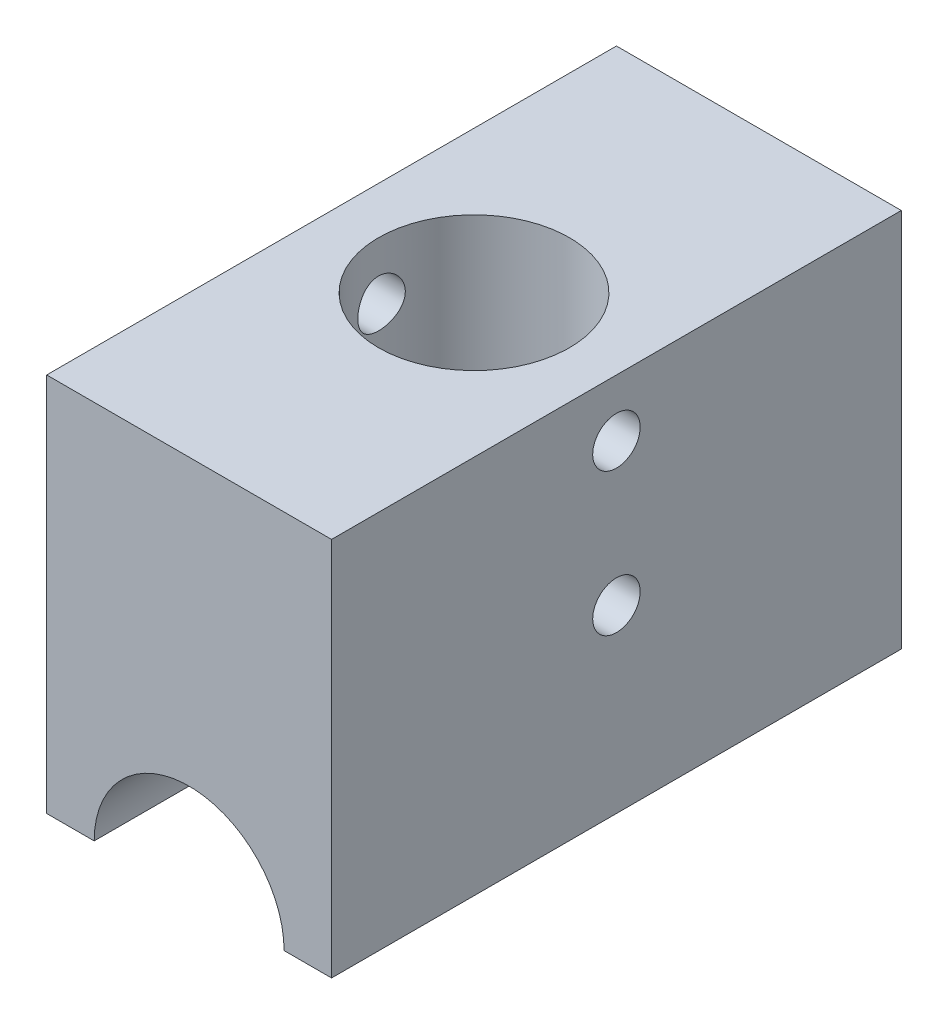
from build123d import *

# Parameters (mm, degrees)
SKETCH1_W           = 38.1
SKETCH1_H           = 50.8
BOSS_EXTRUDE1_DEPTH = 76.2
SKETCH5_R           = 12.7
CUT_EXTRUDE3_DEPTH  = 77.2
SKETCH6_R           = 12.7635
CUT_EXTRUDE4_DEPTH  = 50.8
SKETCH7_R           = 3.175
CUT_EXTRUDE5_DEPTH  = 39.1


with BuildPart() as part:
    # Sketch1 → Boss-Extrude1 (new body)
    with BuildSketch(Plane.XY):
        Rectangle(SKETCH1_W, SKETCH1_H)
    extrude(amount=BOSS_EXTRUDE1_DEPTH)

    # Sketch5 → Cut-Extrude3 (cut, through all)
    with BuildSketch(Plane(origin=(0, 0, 0), x_dir=(-1, 0, 0), z_dir=(0, 0, -1))):
        with Locations((0, -25.4)):
            Circle(SKETCH5_R)
    extrude(amount=-CUT_EXTRUDE3_DEPTH, mode=Mode.SUBTRACT)

    # Sketch6 → Cut-Extrude4 (cut)
    with BuildSketch(Plane(origin=(0, 25.4, 0), x_dir=(1, 0, 0), z_dir=(0, 1, 0))):
        with Locations((0, -38.1)):
            Circle(SKETCH6_R)
    extrude(amount=-CUT_EXTRUDE4_DEPTH, mode=Mode.SUBTRACT)

    # Sketch7 → Cut-Extrude5 (cut, through all)
    with BuildSketch(Plane(origin=(19.05, 0, 0), x_dir=(0, 0, -1), z_dir=(1, 0, 0))):
        with Locations((-38.1, 17.78)):
            Circle(SKETCH7_R)
        with Locations((-38.1, -1.27)):
            Circle(SKETCH7_R)
    extrude(amount=-CUT_EXTRUDE5_DEPTH, mode=Mode.SUBTRACT)


solid = part.part
